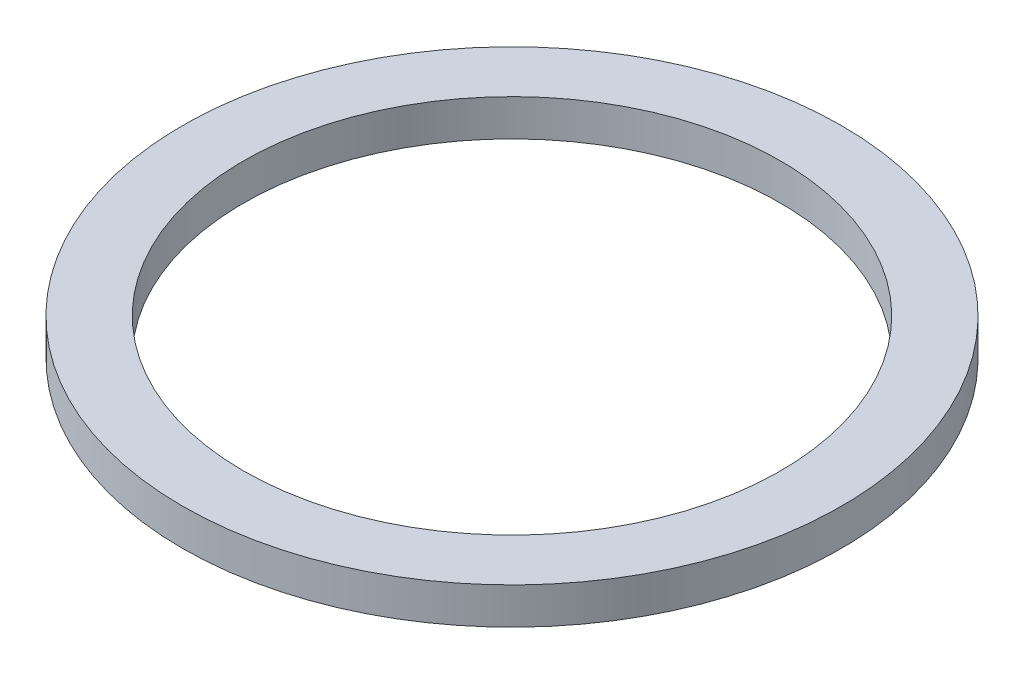
from build123d import *

# Parameters (mm, degrees)
SKETCH1_R           = 27
SKETCH1_R_2         = 22
BOSS_EXTRUDE1_DEPTH = 3


with BuildPart() as part:
    # Sketch1 → Boss-Extrude1 (new body)
    with BuildSketch(Plane(origin=(0, 0, 0), x_dir=(1, 0, 0), z_dir=(0, 1, 0))):
        with Locations(Location((0, 0, 0), (0, 0, 270))):  # turned: the seam where the file's is
            Circle(SKETCH1_R)
        with Locations(Location((0, 0, 0), (0, 0, 270))):  # turned: the seam where the file's is
            Circle(SKETCH1_R_2, mode=Mode.SUBTRACT)
    extrude(amount=BOSS_EXTRUDE1_DEPTH)


solid = part.part
